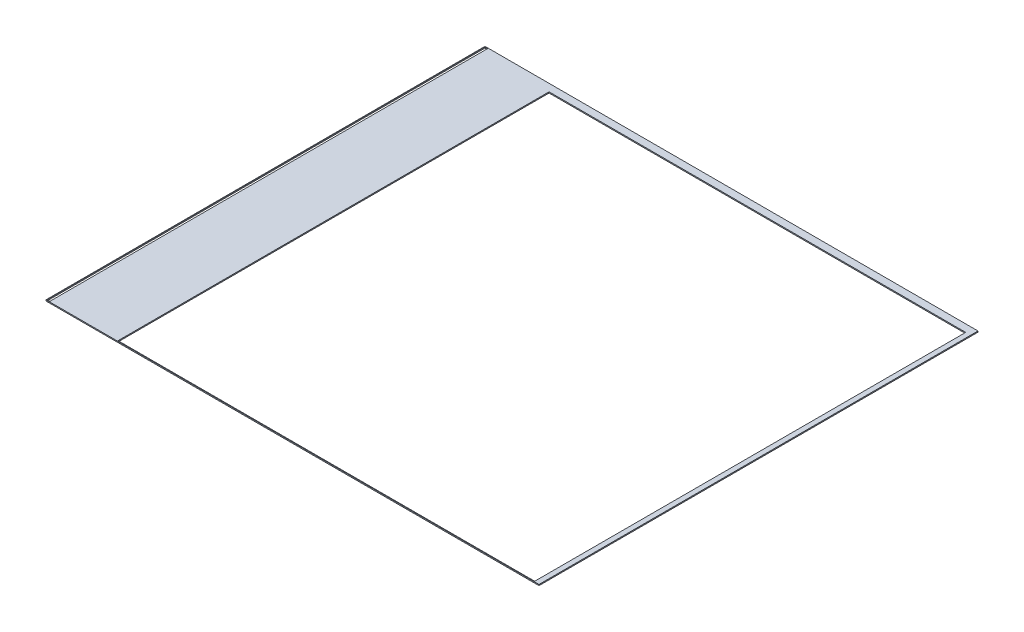
from build123d import *

# Parameters (mm, degrees)
SKETCH1_W          = 22.73
SKETCH1_H          = 20.24
EXTRUDE1_DEPTH     = 0.05
SKETCH2_W          = 0.13
SKETCH2_H          = 20.185
CUT_EXTRUDE1_DEPTH = 1.05
SKETCH3_W          = 19.2096
SKETCH3_H          = 19.872
CUT_EXTRUDE2_DEPTH = 1.05


with BuildPart() as part:
    # Sketch1 → Extrude1 (new body)
    with BuildSketch(Plane(origin=(0, 0, 0), x_dir=(1, 0, 0), z_dir=(0, 1, 0))):
        Rectangle(SKETCH1_W, SKETCH1_H)
    extrude(amount=EXTRUDE1_DEPTH)

    # Sketch2 → Cut-Extrude1 (cut, through all)
    with BuildSketch(Plane.XZ):
        with Locations((-11.2796, -0.00435)):
            Rectangle(SKETCH2_W, SKETCH2_H)
    extrude(amount=-CUT_EXTRUDE1_DEPTH, mode=Mode.SUBTRACT)

    # Sketch3 → Cut-Extrude2 (cut, through all)
    with BuildSketch(Plane.XZ):
        with Locations((1.533, 0.155375)):
            Rectangle(SKETCH3_W, SKETCH3_H)
    extrude(amount=-CUT_EXTRUDE2_DEPTH, mode=Mode.SUBTRACT)


solid = part.part
